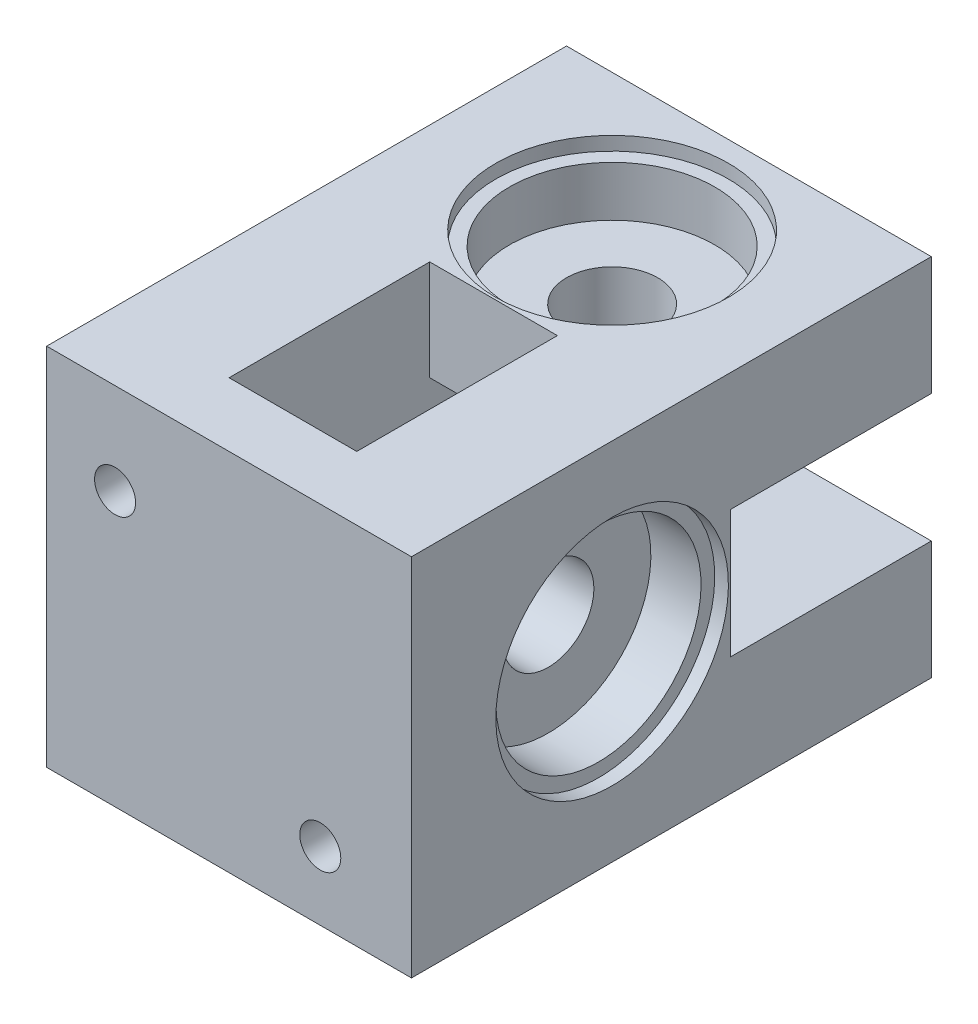
from build123d import *

# Parameters (mm, degrees)
ESQUISSE1_W              = 40
ESQUISSE1_H              = 40
BOSS_EXTRU_1_DEPTH       = 50
ESQUISSE2_R              = 5
ENL_V_MAT_EXTRU_1_DEPTH  = 41
ESQUISSE3_R              = 5
ENL_V_MAT_EXTRU_2_DEPTH  = 41
ESQUISSE4_W              = 20
ESQUISSE4_H              = 14
ENL_V_MAT_EXTRU_3_DEPTH  = 29
ESQUISSE5_W              = 14
ESQUISSE5_H              = 20
ENL_V_MAT_EXTRU_4_DEPTH  = 29
ESQUISSE6_W              = 22
ESQUISSE6_H              = 14
ENL_V_MAT_EXTRU_5_DEPTH  = 24
ESQUISSE7_W              = 14
ESQUISSE7_H              = 22
ENL_V_MAT_EXTRU_6_DEPTH  = 24
ESQUISSE8_R              = 11.25
ENL_V_MAT_EXTRU_7_DEPTH  = 7
ESQUISSE9_R              = 12.75
ENL_V_MAT_EXTRU_8_DEPTH  = 1.5
ESQUISSE10_R             = 11.25
ENL_V_MAT_EXTRU_9_DEPTH  = 7
ESQUISSE11_R             = 12.75
ENL_V_MAT_EXTRU_10_DEPTH = 1.5
ESQUISSE12_W             = 40
ESQUISSE12_H             = 40
BOSS_EXTRU_2_DEPTH       = 7
ESQUISSE13_R             = 2.25
ENL_V_MAT_EXTRU_11_DEPTH = 15
ESQUISSE14_W             = 7.5
ESQUISSE14_H             = 3.5
ENL_V_MAT_EXTRU_12_DEPTH = 12
ESQUISSE15_W             = 3.5
ESQUISSE15_H             = 7.5
ENL_V_MAT_EXTRU_13_DEPTH = 12


with BuildPart() as part:
    # Esquisse1 → Boss.-Extru.1 (new body)
    with BuildSketch(Plane.XY):
        with Locations((-20, 20)):
            Rectangle(ESQUISSE1_W, ESQUISSE1_H)
    extrude(amount=BOSS_EXTRU_1_DEPTH)

    # Esquisse2 → Enlèv. mat.-Extru.1 (cut, through all)
    with BuildSketch(Plane(origin=(0, 40, 0), x_dir=(1, 0, 0), z_dir=(0, 1, 0))):
        with Locations(Location((-20, -15, 0), (0, 0, 270))):  # turned: the seam where the file's is
            Circle(ESQUISSE2_R)
    extrude(amount=-ENL_V_MAT_EXTRU_1_DEPTH, mode=Mode.SUBTRACT)

    # Esquisse3 → Enlèv. mat.-Extru.2 (cut, through all)
    with BuildSketch(Plane.ZY.offset(40)):
        with Locations((35, 20)):
            Circle(ESQUISSE3_R)
    extrude(amount=-ENL_V_MAT_EXTRU_2_DEPTH, mode=Mode.SUBTRACT)

    # Esquisse4 → Enlèv. mat.-Extru.3 (cut)
    with BuildSketch(Plane.ZY.offset(40)):
        with Locations((15, 20)):
            Rectangle(ESQUISSE4_W, ESQUISSE4_H)
    extrude(amount=-ENL_V_MAT_EXTRU_3_DEPTH, mode=Mode.SUBTRACT)

    # Esquisse5 → Enlèv. mat.-Extru.4 (cut)
    with BuildSketch(Plane.XZ):
        with Locations((-20, 35)):
            Rectangle(ESQUISSE5_W, ESQUISSE5_H)
    extrude(amount=-ENL_V_MAT_EXTRU_4_DEPTH, mode=Mode.SUBTRACT)

    # Esquisse6 → Enlèv. mat.-Extru.5 (cut)
    with BuildSketch(Plane(origin=(0, 0, 0), x_dir=(0, 0, -1), z_dir=(1, 0, 0))):
        with Locations((-11, 20)):
            Rectangle(ESQUISSE6_W, ESQUISSE6_H)
    extrude(amount=-ENL_V_MAT_EXTRU_5_DEPTH, mode=Mode.SUBTRACT)

    # Esquisse7 → Enlèv. mat.-Extru.6 (cut)
    with BuildSketch(Plane(origin=(0, 40, 0), x_dir=(1, 0, 0), z_dir=(0, 1, 0))):
        with Locations((-20, -39)):
            Rectangle(ESQUISSE7_W, ESQUISSE7_H)
    extrude(amount=-ENL_V_MAT_EXTRU_6_DEPTH, mode=Mode.SUBTRACT)

    # Esquisse8 → Enlèv. mat.-Extru.7 (cut)
    with BuildSketch(Plane(origin=(0, 0, 0), x_dir=(0, 0, -1), z_dir=(1, 0, 0))):
        with Locations(Location((-35, 20, 0), (0, 0, 90))):  # turned: the seam where the file's is
            Circle(ESQUISSE8_R)
    extrude(amount=-ENL_V_MAT_EXTRU_7_DEPTH, mode=Mode.SUBTRACT)

    # Esquisse9 → Enlèv. mat.-Extru.8 (cut)
    with BuildSketch(Plane(origin=(0, 0, 0), x_dir=(0, 0, -1), z_dir=(1, 0, 0))):
        with Locations(Location((-35, 20, 0), (0, 0, 90))):  # turned: the seam where the file's is
            Circle(ESQUISSE9_R)
    extrude(amount=-ENL_V_MAT_EXTRU_8_DEPTH, mode=Mode.SUBTRACT)

    # Esquisse10 → Enlèv. mat.-Extru.9 (cut)
    with BuildSketch(Plane(origin=(0, 40, 0), x_dir=(1, 0, 0), z_dir=(0, 1, 0))):
        with Locations(Location((-20, -15, 0), (0, 0, 270))):  # turned: the seam where the file's is
            Circle(ESQUISSE10_R)
    extrude(amount=-ENL_V_MAT_EXTRU_9_DEPTH, mode=Mode.SUBTRACT)

    # Esquisse11 → Enlèv. mat.-Extru.10 (cut)
    with BuildSketch(Plane(origin=(0, 40, 0), x_dir=(1, 0, 0), z_dir=(0, 1, 0))):
        with Locations(Location((-20, -15, 0), (0, 0, 270))):  # turned: the seam where the file's is
            Circle(ESQUISSE11_R)
    extrude(amount=-ENL_V_MAT_EXTRU_10_DEPTH, mode=Mode.SUBTRACT)

    # Esquisse12 → Boss.-Extru.2 (add)
    with BuildSketch(Plane.XY.offset(50)):
        with Locations((-20, 20)):
            Rectangle(ESQUISSE12_W, ESQUISSE12_H)
    extrude(amount=BOSS_EXTRU_2_DEPTH)

    # Esquisse13 → Enlèv. mat.-Extru.11 (cut)
    with BuildSketch(Plane.XY.offset(57)):
        with Locations((-32.5, 30)):
            Circle(ESQUISSE13_R)
        with Locations((-10, 7.5)):
            Circle(ESQUISSE13_R)
    extrude(amount=-ENL_V_MAT_EXTRU_11_DEPTH, mode=Mode.SUBTRACT)

    # Esquisse14 → Enlèv. mat.-Extru.12 (cut)
    with BuildSketch(Plane.XZ):
        with Locations((-10, 51.25)):
            Rectangle(ESQUISSE14_W, ESQUISSE14_H)
    extrude(amount=-ENL_V_MAT_EXTRU_12_DEPTH, mode=Mode.SUBTRACT)

    # Esquisse15 → Enlèv. mat.-Extru.13 (cut)
    with BuildSketch(Plane.ZY.offset(40)):
        with Locations((51.25, 30)):
            Rectangle(ESQUISSE15_W, ESQUISSE15_H)
    extrude(amount=-ENL_V_MAT_EXTRU_13_DEPTH, mode=Mode.SUBTRACT)


solid = part.part
